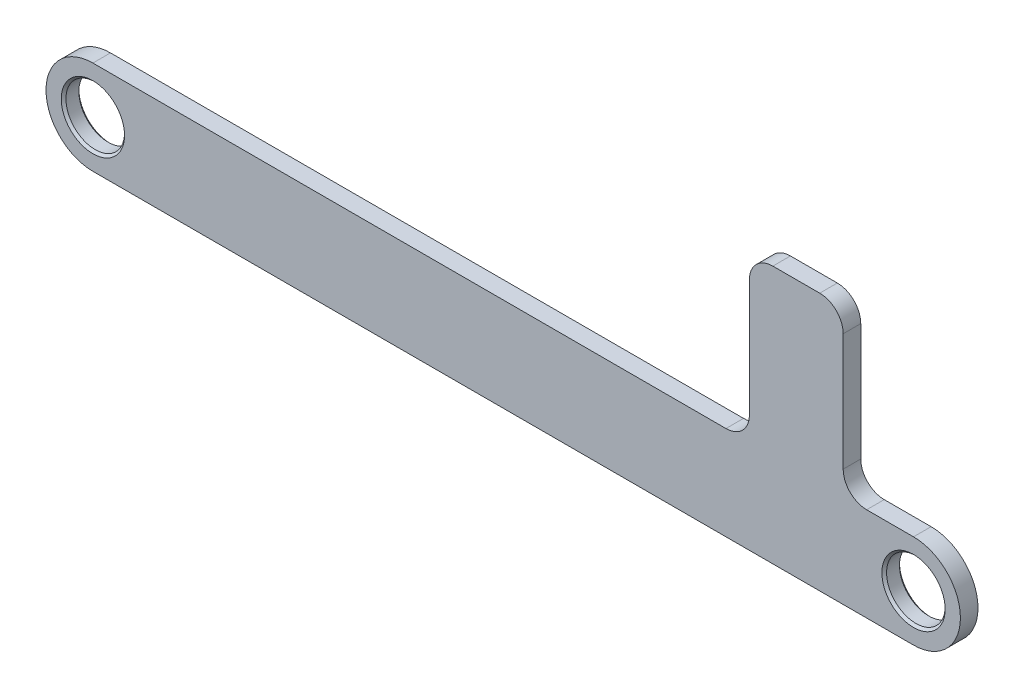
from build123d import *

# Parameters (mm, degrees)
ESQUISSE1_R      = 2.5
EXTRUSION1_DEPTH = 0.75
CONG_1_R         = 2
CHANFREIN1_SIZE  = 0.2


with BuildPart() as part:
    # Esquisse1 → Extrusion1 (new body, symmetric)
    with BuildSketch(Plane.XY):
        with BuildLine():
            Line((-70, 4), (-14, 4))
            Line((-14, 4), (-14, 18))
            Line((-14, 18), (-6, 18))
            Line((-6, 18), (-6, 4))
            Line((-6, 4), (0, 4))
            ThreePointArc((0, 4), (4, 0), (0, -4))
            Line((0, -4), (-70, -4))
            ThreePointArc((-70, -4), (-74, 0), (-70, 4))
        make_face()
        with Locations((-70, 0)):
            Circle(ESQUISSE1_R, mode=Mode.SUBTRACT)
        Circle(ESQUISSE1_R, mode=Mode.SUBTRACT)
    extrude(amount=EXTRUSION1_DEPTH, both=True)

    # Congé1
    cong_1_edges = [part.edges().sort_by_distance(p)[0] for p in [
        (-14, 4, 0),
        (-14, 18, 0),
        (-6, 18, 0),
        (-6, 4, 0),
    ]]
    fillet(cong_1_edges, radius=CONG_1_R)

    # Chanfrein1
    chanfrein1_edges = [part.edges().sort_by_distance(p)[0] for p in [
        (-72.5, 0, -0.75),
        (-72.5, 0, 0.75),
        (-2.5, 0, -0.75),
        (-2.5, 0, 0.75),
    ]]
    chamfer(chanfrein1_edges, length=CHANFREIN1_SIZE)


solid = part.part
